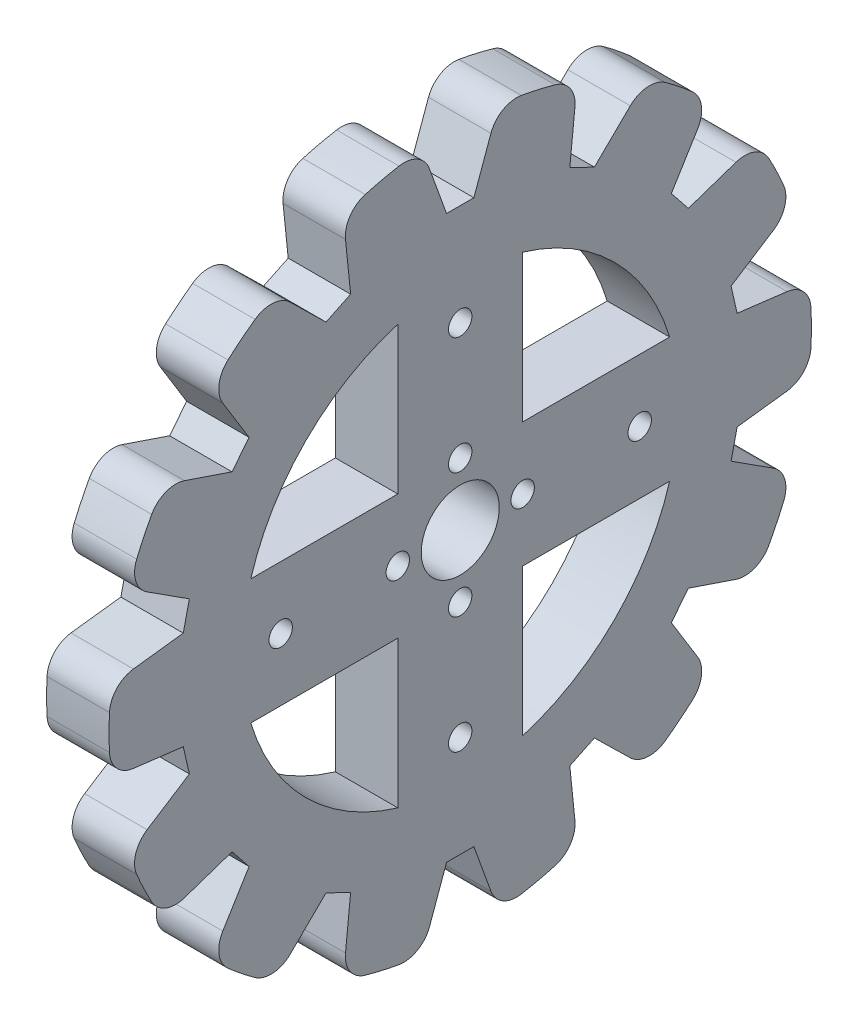
from build123d import *

# Parameters (mm, degrees)
SPROCKET_R                   = 45
ESTRUSIONE_ESTRUSIONE2_DEPTH = 8
TAGLIO_ESTRUSIONE1_DEPTH     = 9
RACCORDO1_R                  = 3.5
SCHIZZO1_R                   = 5
SCHIZZO1_R_2                 = 1.5
TAGLIO_ESTRUSIONE2_DEPTH     = 9
TAGLIO_ESTRUSIONE3_DEPTH     = 9


with BuildPart() as part:
    # Sprocket → Estrusione-Estrusione2 (new body)
    with BuildSketch(Plane(origin=(0, 0, 0), x_dir=(0, 0, -1), z_dir=(1, 0, 0))):
        Circle(SPROCKET_R)
    extrude(amount=ESTRUSIONE_ESTRUSIONE2_DEPTH)

    # Tooth → Taglio-Estrusione1 (cut, through all)
    with BuildSketch(Plane(origin=(0, 0, 0), x_dir=(0, 0, -1), z_dir=(1, 0, 0))):
        Polygon((-5, 45), (5, 45), (1.75, 36), (-1.75, 36), align=None)
        Polygon((24.0296126, 38.37418036), (17.196510127, 31.675582701), (14.043119089, 33.194175788), (15.019923921, 42.713017751), align=None)
        Polygon((38.29986572, 24.147883671), (29.237040522, 21.077427773), (27.054826216, 23.813837961), (32.064967702, 31.966198496), align=None)
        Polygon((44.984360718, 5.138802467), (35.486816473, 6.304629776), (34.707993204, 9.716877469), (42.759151378, 14.888081589), align=None)
        Polygon((42.759151378, -14.888081589), (34.707993204, -9.716877469), (35.486816473, -6.304629776), (44.984360718, -5.138802467), align=None)
        Polygon((32.064967702, -31.966198496), (27.054826216, -23.813837961), (29.237040522, -21.077427773), (38.29986572, -24.147883671), align=None)
        Polygon((15.019923921, -42.713017751), (14.043119089, -33.194175788), (17.196510127, -31.675582701), (24.0296126, -38.37418036), align=None)
        Polygon((-5, -45), (-1.75, -36), (1.75, -36), (5, -45), align=None)
        Polygon((-24.0296126, -38.37418036), (-17.196510127, -31.675582701), (-14.043119089, -33.194175788), (-15.019923921, -42.713017751), align=None)
        Polygon((-38.29986572, -24.147883671), (-29.237040522, -21.077427773), (-27.054826216, -23.813837961), (-32.064967702, -31.966198496), align=None)
        Polygon((-44.984360718, -5.138802467), (-35.486816473, -6.304629776), (-34.707993204, -9.716877469), (-42.759151378, -14.888081589), align=None)
        Polygon((-42.759151378, 14.888081589), (-34.707993204, 9.716877469), (-35.486816473, 6.304629776), (-44.984360718, 5.138802467), align=None)
        Polygon((-32.064967702, 31.966198496), (-27.054826216, 23.813837961), (-29.237040522, 21.077427773), (-38.29986572, 24.147883671), align=None)
        Polygon((-15.019923921, 42.713017751), (-14.043119089, 33.194175788), (-17.196510127, 31.675582701), (-24.0296126, 38.37418036), align=None)
    extrude(amount=TAGLIO_ESTRUSIONE1_DEPTH, mode=Mode.SUBTRACT)

    # Raccordo1
    raccordo1_edges = [part.edges().sort_by_distance(p)[0] for p in [
        (4, -5.173509038, -44.701619705),
        (4, -14.734135321, -42.519469145),
        (4, -24.056476483, -38.030066253),
        (4, -31.723503477, -31.915816253),
        (4, 44.732070833, 4.903247801),
        (4, 44.732070833, -4.903247801),
        (4, -38.174763728, -23.826191772),
        (4, -42.429642707, -14.990844531),
        (4, -44.732070833, -4.903247801),
        (4, -44.732070833, 4.903247801),
        (4, -42.429642707, 14.990844531),
        (4, -38.174763728, 23.826191772),
        (4, -31.723503477, 31.915816253),
        (4, -24.056476483, 38.030066253),
        (4, -14.734135321, 42.519469145),
        (4, -5.173509038, 44.701619705),
        (4, 5.173509038, 44.701619705),
        (4, 14.734135321, 42.519469145),
        (4, 24.056476483, 38.030066253),
        (4, 31.723503477, 31.915816253),
        (4, 38.174763728, 23.826191772),
        (4, 42.429642707, 14.990844531),
        (4, 42.429642707, -14.990844531),
        (4, 38.174763728, -23.826191772),
        (4, 31.723503477, -31.915816253),
        (4, 24.056476483, -38.030066253),
        (4, 14.734135321, -42.519469145),
        (4, 5.173509038, -44.701619705),
    ]]
    fillet(raccordo1_edges, radius=RACCORDO1_R)

    # Schizzo1 → Taglio-Estrusione2 (cut, through all)
    with BuildSketch(Plane(origin=(0, 0, 0), x_dir=(0, 0, -1), z_dir=(1, 0, 0))):
        Circle(SCHIZZO1_R)
        with Locations((0, 8)):
            Circle(SCHIZZO1_R_2)
        with Locations((8, 0)):
            Circle(SCHIZZO1_R_2)
        with Locations((0, -8)):
            Circle(SCHIZZO1_R_2)
        with Locations((-8, 0)):
            Circle(SCHIZZO1_R_2)
        with Locations((0, 23)):
            Circle(SCHIZZO1_R_2)
        with Locations((23, 0)):
            Circle(SCHIZZO1_R_2)
        with Locations((0, -23)):
            Circle(SCHIZZO1_R_2)
        with Locations((-23, 0)):
            Circle(SCHIZZO1_R_2)
    extrude(amount=TAGLIO_ESTRUSIONE2_DEPTH, mode=Mode.SUBTRACT)

    # Schizzo2 → Taglio-Estrusione3 (cut, through all)
    with BuildSketch(Plane(origin=(8, 0, 0), x_dir=(0, 0, -1), z_dir=(1, 0, 0))):
        with BuildLine():
            Line((-26.83281573, 8), (-8, 8))
            Line((-8, 8), (-8, 26.83281573))
            ThreePointArc((-8, 26.83281573), (-19.798989873, 19.798989873), (-26.83281573, 8))
        make_face()
        with BuildLine():
            Line((26.83281573, 8), (8, 8))
            Line((8, 8), (8, 26.83281573))
            ThreePointArc((8, 26.83281573), (19.798989873, 19.798989873), (26.83281573, 8))
        make_face()
        with BuildLine():
            Line((8, -26.83281573), (8, -8))
            Line((8, -8), (26.83281573, -8))
            ThreePointArc((26.83281573, -8), (19.798989873, -19.798989873), (8, -26.83281573))
        make_face()
        with BuildLine():
            Line((-26.83281573, -8), (-8, -8))
            Line((-8, -8), (-8, -26.83281573))
            ThreePointArc((-8, -26.83281573), (-19.798989873, -19.798989873), (-26.83281573, -8))
        make_face()
    extrude(amount=-TAGLIO_ESTRUSIONE3_DEPTH, mode=Mode.SUBTRACT)


solid = part.part
